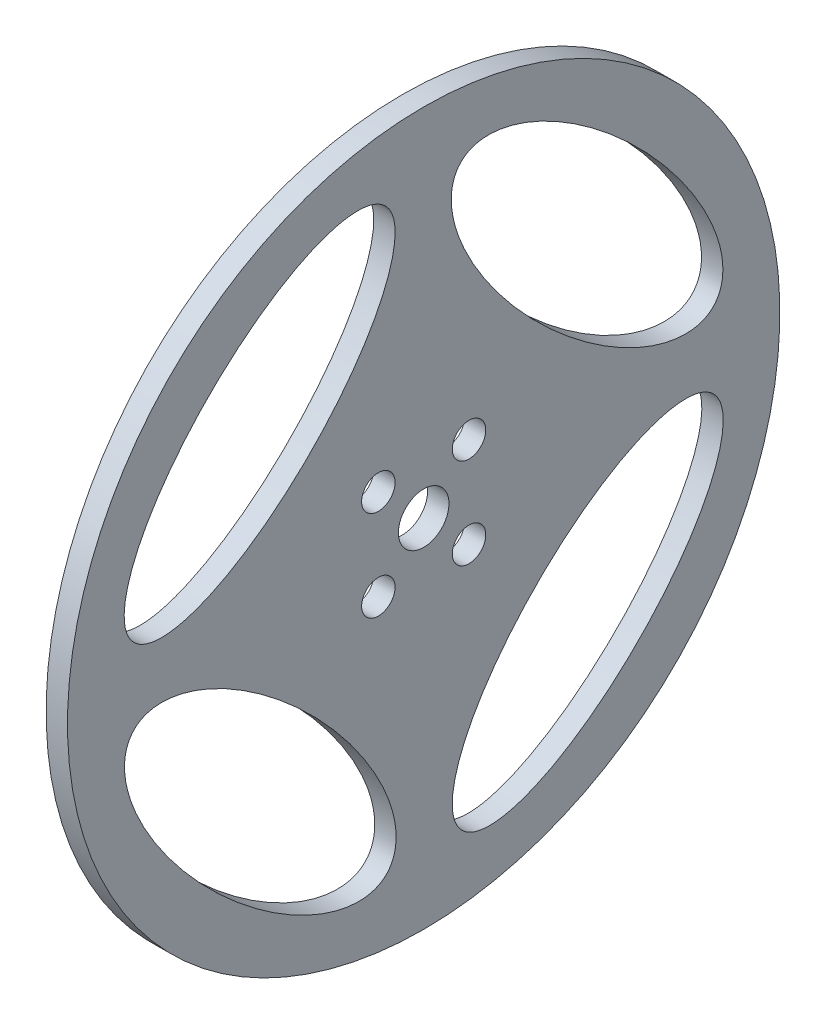
from build123d import *

# Parameters (mm, degrees)
SKIZZE1_W                        = 3
SKIZZE1_H                        = 46.45
F_4_7_4_7_DURCHMESSER_BOHRUNG1_D = 4.7
SKIZZE5_RX                       = 25
SKIZZE5_RY                       = 10
SCHNITT_LINEAR_AUSTRAGEN1_DEPTH  = 3
KREISMUSTER1_COUNT               = 4


with BuildPart() as part:
    # Skizze1 → Rotation1 (revolve)
    with BuildSketch(Plane.XY):
        with Locations((-39.553372853, 36.525)):
            Rectangle(SKIZZE1_W, SKIZZE1_H)
    revolve(axis=Axis((-17.6629112, 9.75, 0), (-1, 0, 0)))

    # Ø4.7 (4.7) Durchmesser Bohrung1 (through all)
    with Locations(Plane(origin=(-41.053372853, 11.968723204, 19.868936148), x_dir=(0, 0, 1), z_dir=(-1, 0, 0))):
        with Locations((-13.504975118, -8.582684234), (-26.232897179, -8.582684234), (-26.232897179, 4.145237827), (-13.504975118, 4.145237827)):
            Hole(F_4_7_4_7_DURCHMESSER_BOHRUNG1_D / 2)

    # Skizze5 → Schnitt-Linear austragen1 (cut)
    with BuildSketch(Plane(origin=(-38.053372853, 0, 0), x_dir=(0, 0, -1), z_dir=(1, 0, 0))):
        with Locations(Location((-23.027329597, 32.684515508), (0, 0, 45.090609512))):
            Ellipse(SKIZZE5_RX, SKIZZE5_RY)
    schnitt_linear_austragen1 = extrude(amount=-SCHNITT_LINEAR_AUSTRAGEN1_DEPTH, mode=Mode.SUBTRACT)

    # Kreismuster1: Schnitt-Linear austragen1 ×4 about axis
    kreismuster1_axis = Axis((0, 9.75, 0), (-1, 0, 0))
    for i in range(1, KREISMUSTER1_COUNT):
        add(schnitt_linear_austragen1.rotate(kreismuster1_axis, i * 360 / KREISMUSTER1_COUNT), mode=Mode.SUBTRACT)


solid = part.part
